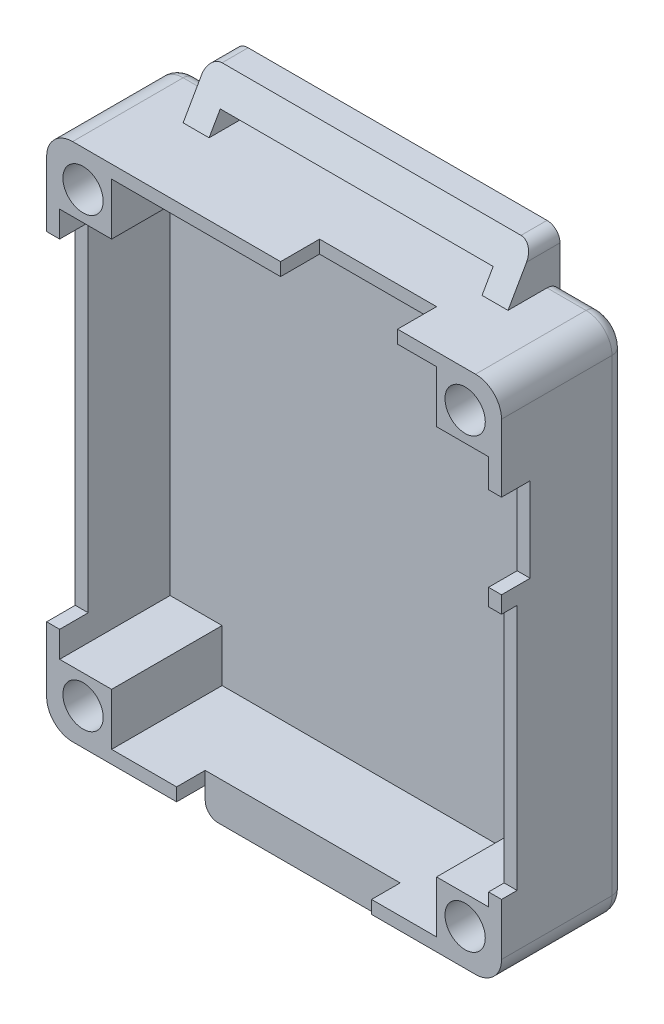
from build123d import *

# Parameters (mm, degrees)
SKETCH_1_W               = 35
SKETCH_1_H               = 40
EXTRUDE_1_DEPTH          = 9.5
SHELL_1_T                = -1
SKETCH_2_W               = 4
SKETCH_2_H               = 4
EXTRUDE_2_DEPTH          = 8.5
MIRROR_4_COPY_1_SKETCH_W = 4
MIRROR_4_COPY_1_SKETCH_H = 4
MIRROR_4_COPY_1_DEPTH    = 8.5
SKETCH_3_R               = 1.55
CUT_EXTRUDE_1_DEPTH      = 12
MIRROR_6_COPY_1_SKETCH_R = 1.55
MIRROR_6_COPY_1_DEPTH    = 12
SKETCH_6_R               = 1.55
EXTRUDE_3_DEPTH          = 1.5
MIRROR_8_COPY_1_SKETCH_R = 1.55
MIRROR_8_COPY_1_DEPTH    = 1.5
SKETCH_7_W               = 9
SKETCH_7_H               = 1
CUT_EXTRUDE_2_DEPTH      = 3
SKETCH_8_W               = 1
SKETCH_8_H               = 26
CUT_EXTRUDE_3_DEPTH      = 2.2
SKETCH_9_W               = 1
SKETCH_9_H               = 19
CUT_EXTRUDE_4_DEPTH      = 1.2
SKETCH_10_W              = 1
SKETCH_10_H              = 6.5
CUT_EXTRUDE_5_DEPTH      = 2.2
SKETCH_11_W              = 15
SKETCH_11_H              = 1
CUT_EXTRUDE_6_DEPTH      = 2.2
SKETCH_12_W              = 25
SKETCH_12_H              = 4
EXTRUDE_4_DEPTH          = 3.5
SKETCH_13_W              = 21
SKETCH_13_H              = 1.5
CUT_EXTRUDE_7_DEPTH      = 5
CUT_EXTRUDE_8_DEPTH      = 50
SKETCH_15_W              = 15
SKETCH_15_H              = 2
EXTRUDE_5_DEPTH          = 2
FILLET_1_R               = 2
FILLET_2_R               = 1
FILLET_3_R               = 1
FILLET_4_R               = 1
SKETCH_16_W              = 9
SKETCH_16_H              = 1
EXTRUDE_6_DEPTH          = 3


with BuildPart() as part:
    # 草图1 → 凸台-拉伸1 (new body)
    with BuildSketch(Plane.XY):
        Rectangle(SKETCH_1_W, SKETCH_1_H)
    extrude(amount=EXTRUDE_1_DEPTH)

    # 抽壳1
    shell_1_openings = [part.faces().sort_by_distance(p)[0] for p in [
        (0, 0, 9.5),
    ]]
    offset(amount=SHELL_1_T, openings=shell_1_openings, kind=Kind.INTERSECTION)

    # 草图2 → 凸台-拉伸2 (add)
    with BuildSketch(Plane.XY.offset(1)):
        with Locations((-14.5, 17)):
            Rectangle(SKETCH_2_W, SKETCH_2_H)
    extrude_2 = extrude(amount=EXTRUDE_2_DEPTH)

    # 镜向3: 凸台-拉伸2 across plane
    add(extrude_2.mirror(Plane.ZX))

    # 镜向4: 凸台-拉伸2 across plane
    add(extrude_2.mirror(Plane(origin=(0, 0, 0), x_dir=(0, 0, 1), z_dir=(1, 0, 0))))

    # 镜向4 copy 1 sketch → 镜向4 copy 1 (add)
    with BuildSketch(Plane(origin=(0, 0, 1), x_dir=(-1, 0, 0), z_dir=(0, 0, 1))):
        with Locations((-14.5, 17)):
            Rectangle(MIRROR_4_COPY_1_SKETCH_W, MIRROR_4_COPY_1_SKETCH_H)
    extrude(amount=MIRROR_4_COPY_1_DEPTH)

    # 草图3 → 切除-拉伸1 (cut)
    with BuildSketch(Plane(origin=(0, 0, 0), x_dir=(-1, 0, 0), z_dir=(0, 0, -1))):
        with Locations((-14.7, 17.2)):
            Circle(SKETCH_3_R)
    cut_extrude_1 = extrude(amount=-CUT_EXTRUDE_1_DEPTH, mode=Mode.SUBTRACT)

    # 镜向5: 切除-拉伸1 across plane
    add(cut_extrude_1.mirror(Plane.ZX), mode=Mode.SUBTRACT)

    # 镜向6: 切除-拉伸1 across plane
    add(cut_extrude_1.mirror(Plane(origin=(0, 0, 0), x_dir=(0, 0, 1), z_dir=(1, 0, 0))), mode=Mode.SUBTRACT)

    # 镜向6 copy 1 sketch → 镜向6 copy 1 (cut)
    with BuildSketch(Plane(origin=(0, 0, 0), x_dir=(1, 0, 0), z_dir=(0, 0, -1))):
        with Locations((-14.7, 17.2)):
            Circle(MIRROR_6_COPY_1_SKETCH_R)
    extrude(amount=-MIRROR_6_COPY_1_DEPTH, mode=Mode.SUBTRACT)

    # 草图6 → 凸台-拉伸3 (add)
    with BuildSketch(Plane(origin=(0, 0, 0), x_dir=(-1, 0, 0), z_dir=(0, 0, -1))):
        with Locations((-14.7, 17.2)):
            Circle(SKETCH_6_R)
    extrude_3 = extrude(amount=-EXTRUDE_3_DEPTH)

    # 镜向7: 凸台-拉伸3 across plane
    add(extrude_3.mirror(Plane.ZX))

    # 镜向8: 凸台-拉伸3 across plane
    add(extrude_3.mirror(Plane(origin=(0, 0, 0), x_dir=(0, 0, 1), z_dir=(1, 0, 0))))

    # 镜向8 copy 1 sketch → 镜向8 copy 1 (add)
    with BuildSketch(Plane(origin=(0, 0, 0), x_dir=(1, 0, 0), z_dir=(0, 0, -1))):
        with Locations((-14.7, 17.2)):
            Circle(MIRROR_8_COPY_1_SKETCH_R)
    extrude(amount=-MIRROR_8_COPY_1_DEPTH)

    # 草图7 → 切除-拉伸2 (cut)
    with BuildSketch(Plane.XY.offset(9.5)):
        with Locations((-5, 19.5)):
            Rectangle(SKETCH_7_W, SKETCH_7_H)
    cut_extrude_2 = extrude(amount=-CUT_EXTRUDE_2_DEPTH, mode=Mode.SUBTRACT)

    # 草图8 → 切除-拉伸3 (cut)
    with BuildSketch(Plane.XY.offset(9.5)):
        with Locations((-17, 0)):
            Rectangle(SKETCH_8_W, SKETCH_8_H)
    extrude(amount=-CUT_EXTRUDE_3_DEPTH, mode=Mode.SUBTRACT)

    # 草图9 → 切除-拉伸4 (cut)
    with BuildSketch(Plane.XY.offset(9.5)):
        with Locations((17, -4.5)):
            Rectangle(SKETCH_9_W, SKETCH_9_H)
    extrude(amount=-CUT_EXTRUDE_4_DEPTH, mode=Mode.SUBTRACT)

    # 草图10 → 切除-拉伸5 (cut)
    with BuildSketch(Plane.XY.offset(9.5)):
        with Locations((17, 9.55)):
            Rectangle(SKETCH_10_W, SKETCH_10_H)
    extrude(amount=-CUT_EXTRUDE_5_DEPTH, mode=Mode.SUBTRACT)

    # 草图11 → 切除-拉伸6 (cut)
    with BuildSketch(Plane.XY.offset(9.5)):
        with Locations((0, -19.5)):
            Rectangle(SKETCH_11_W, SKETCH_11_H)
    extrude(amount=-CUT_EXTRUDE_6_DEPTH, mode=Mode.SUBTRACT)

    # 草图12 → 凸台-拉伸4 (add)
    with BuildSketch(Plane.XZ.offset(20)):
        with Locations((0, 2)):
            Rectangle(SKETCH_12_W, SKETCH_12_H)
    extrude_4 = extrude(amount=EXTRUDE_4_DEPTH)

    # 草图13 → 切除-拉伸7 (cut)
    with BuildSketch(Plane.XY.offset(4)):
        with Locations((0, -20.75)):
            Rectangle(SKETCH_13_W, SKETCH_13_H)
    cut_extrude_7 = extrude(amount=-CUT_EXTRUDE_7_DEPTH, mode=Mode.SUBTRACT)

    # 草图14 → 切除-拉伸8 (cut)
    with BuildSketch(Plane(origin=(12.5, 0, 0), x_dir=(0, 0, -1), z_dir=(1, 0, 0))):
        Polygon((-2, -23.5), (-4, -23.5), (-4, -21.75), (-4, -20), align=None)
    cut_extrude_8 = extrude(amount=-CUT_EXTRUDE_8_DEPTH, mode=Mode.SUBTRACT)

    # 镜向11: 凸台-拉伸4, 切除-拉伸7, 切除-拉伸8 across plane
    add(extrude_4.mirror(Plane.ZX))
    add(cut_extrude_7.mirror(Plane.ZX), mode=Mode.SUBTRACT)
    add(cut_extrude_8.mirror(Plane.ZX), mode=Mode.SUBTRACT)

    # 草图15 → 凸台-拉伸5 (add)
    with BuildSketch(Plane.XZ.offset(20)):
        with Locations((0, 6.3)):
            Rectangle(SKETCH_15_W, SKETCH_15_H)
    extrude(amount=EXTRUDE_5_DEPTH)

    # 圆角1
    fillet_1_edges = [part.edges().sort_by_distance(p)[0] for p in [
        (-17.5, 20, 4.75),
        (17.5, 20, 4.75),
        (17.5, -20, 4.75),
        (-17.5, -20, 4.75),
    ]]
    fillet(fillet_1_edges, radius=FILLET_1_R)

    # 圆角2
    fillet_2_edges = [part.edges().sort_by_distance(p)[0] for p in [
        (14, -20, 0),
        (0, -20, 0),
        (-14, 20, 0),
        (0, 20, 0),
        (-17.5, 0, 0),
        (14, 20, 0),
        (17.5, 0, 0),
        (-14, -20, 0),
        (-16.914213562, -19.414213562, 0),
        (16.914213562, -19.414213562, 0),
        (16.914213562, 19.414213562, 0),
        (-16.914213562, 19.414213562, 0),
    ]]
    fillet(fillet_2_edges, radius=FILLET_2_R)

    # 圆角3
    fillet_3_edges = [part.edges().sort_by_distance(p)[0] for p in [
        (12.5, -23.5, 1),
        (-12.5, -23.5, 1),
        (12.5, 23.5, 1),
        (-12.5, 23.5, 1),
    ]]
    fillet(fillet_3_edges, radius=FILLET_3_R)

    # 圆角4
    fillet_4_edges = [part.edges().sort_by_distance(p)[0] for p in [
        (-7.5, -22, 6.3),
        (0, -22, 5.3),
        (7.5, -22, 6.3),
    ]]
    fillet(fillet_4_edges, radius=FILLET_4_R)

    # 镜向12: 切除-拉伸2 across plane
    add(cut_extrude_2.mirror(Plane(origin=(0, 0, 0), x_dir=(0, 0, 1), z_dir=(1, 0, 0))), mode=Mode.SUBTRACT)

    # 草图16 → 凸台-拉伸6 (add)
    with BuildSketch(Plane.XY.offset(6.5)):
        with Locations((-5, 19.5)):
            Rectangle(SKETCH_16_W, SKETCH_16_H)
    extrude(amount=EXTRUDE_6_DEPTH)


solid = part.part
